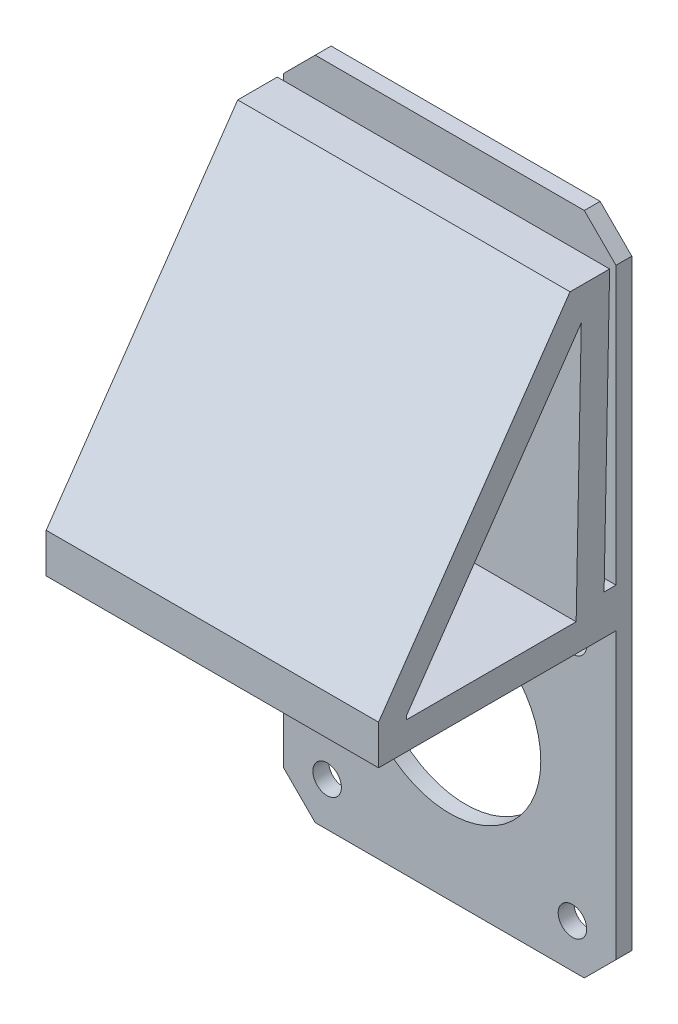
from build123d import *

# Parameters (mm, degrees)
SKETCH1_W            = 42
SKETCH1_H            = 84
SKETCH1_R            = 11.5
BOSS_EXTRUDE1_DEPTH  = 2
M3_CLEARANCE_HOLE1_D = 3.6
CHAMFER1_SIZE        = 4
BOSS_EXTRUDE2_DEPTH  = 42
CUT_EXTRUDE4_DEPTH   = 43


with BuildPart() as part:
    # Sketch1 → Boss-Extrude1 (new body)
    with BuildSketch(Plane.XY):
        with Locations((0, 21)):
            Rectangle(SKETCH1_W, SKETCH1_H)
        Circle(SKETCH1_R, mode=Mode.SUBTRACT)
    extrude(amount=BOSS_EXTRUDE1_DEPTH)

    # M3 Clearance Hole1 (through all)
    with Locations(Plane.XY.offset(2)):
        with Locations((-15.5, 15.5), (15.5, 15.5), (15.5, -15.5), (-15.5, -15.5)):
            Hole(M3_CLEARANCE_HOLE1_D / 2)

    # Chamfer1
    chamfer1_edges = [part.edges().sort_by_distance(p)[0] for p in [
        (-21, 63, 1),
        (21, 63, 1),
        (21, -21, 1),
        (-21, -21, 1),
    ]]
    chamfer(chamfer1_edges, length=CHAMFER1_SIZE)

    # Sketch4 → Boss-Extrude2 (add, through all)
    with BuildSketch(Plane(origin=(21, 0, 0), x_dir=(0, 0, -1), z_dir=(1, 0, 0))):
        Polygon((-32, 24), (-7.8, 59), (-2.8, 59), (-3.5, 24), (-2, 24), (-2, 19), (-32, 19), align=None)
    extrude(amount=-BOSS_EXTRUDE2_DEPTH)

    # Sketch5 → Cut-Extrude4 (cut, through all)
    with BuildSketch(Plane.ZY.offset(21)):
        Polygon((7.03069993, 22.5), (28.5, 22.5), (28.5, 22.907824173), (6.382789422, 54.895525423), align=None)
    extrude(amount=-CUT_EXTRUDE4_DEPTH, mode=Mode.SUBTRACT)


solid = part.part
